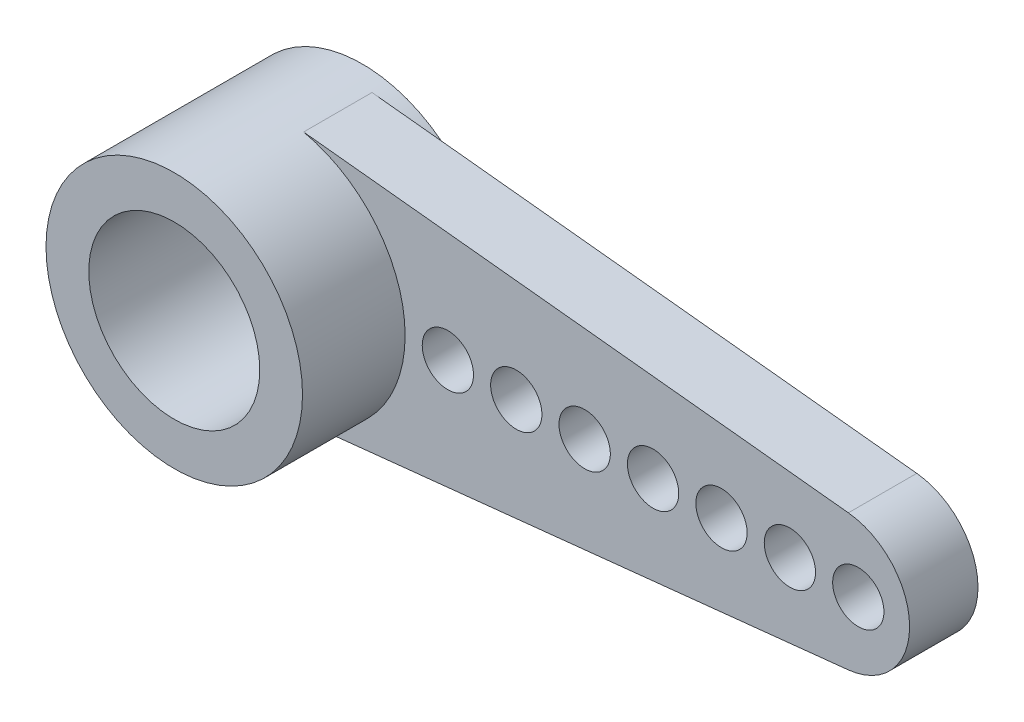
from build123d import *

# Parameters (mm, degrees)
EXTRUDE_3_DEPTH     = 2
SKETCH_2_R          = 3.75
SKETCH_2_R_2        = 2.5
EXTRUDE_5_DEPTH     = 3
SKETCH_3_R          = 3.75
SKETCH_3_R_2        = 2.5
EXTRUDE_6_DEPTH     = 2.5
SKETCH_4_R          = 0.75
CUT_EXTRUDE_1_DEPTH = 2
SKETCH_5_R          = 2.5
EXTRUDE_7_DEPTH     = 1
SKETCH_6_R          = 2.5
CUT_EXTRUDE_2_DEPTH = 0.5
SKETCH_7_R          = 1.25
CUT_EXTRUDE_3_DEPTH = 5


with BuildPart() as part:
    # Эскиз1 → Бобышка-Вытянуть3 (new body)
    with BuildSketch(Plane.XY):
        with BuildLine():
            Line((16.70961775, 1.988984766), (0.781737208, 3.667613248))
            ThreePointArc((0.781737208, 3.667613248), (2.914962652, 2.359129656), (3.75, 0))
            ThreePointArc((3.75, 0), (2.914962652, -2.359129656), (0.781737208, -3.667613248))
            Line((0.781737208, -3.667613248), (16.70961775, -1.988984766))
            ThreePointArc((16.70961775, -1.988984766), (18.5, 0), (16.70961775, 1.988984766))
        make_face()
    extrude(amount=EXTRUDE_3_DEPTH)



with BuildPart() as body_2:
    # Эскиз2 → Бобышка-Вытянуть5 (new body)
    with BuildSketch(Plane.XY.offset(2)):
        Circle(SKETCH_2_R)
        Circle(SKETCH_2_R_2, mode=Mode.SUBTRACT)
    extrude(amount=EXTRUDE_5_DEPTH)


with BuildPart() as part_1:
    add(part.part)

    add(body_2.part)  # Бобышка-Вытянуть6 merges body 2
    # Эскиз3 → Бобышка-Вытянуть6 (add)
    with BuildSketch(Plane(origin=(0, 0, 2), x_dir=(-1, 0, 0), z_dir=(0, 0, -1))):
        Circle(SKETCH_3_R)
        Circle(SKETCH_3_R_2, mode=Mode.SUBTRACT)
    extrude(amount=EXTRUDE_6_DEPTH)

    # Эскиз4 → Вырез-Вытянуть1 (cut)
    with BuildSketch(Plane(origin=(0, 0, 0), x_dir=(-1, 0, 0), z_dir=(0, 0, -1))):
        with Locations((-17, 0)):
            Circle(SKETCH_4_R)
        with Locations((-7, 0)):
            Circle(SKETCH_4_R)
        with Locations((-9, 0)):
            Circle(SKETCH_4_R)
        with Locations((-11, 0)):
            Circle(SKETCH_4_R)
        with Locations((-13, 0)):
            Circle(SKETCH_4_R)
        with Locations((-15, 0)):
            Circle(SKETCH_4_R)
        with Locations((-5, 0)):
            Circle(SKETCH_4_R)
    extrude(amount=-CUT_EXTRUDE_1_DEPTH, mode=Mode.SUBTRACT)

    # Эскиз5 → Бобышка-Вытянуть7 (add)
    with BuildSketch(Plane(origin=(0, 0, 0), x_dir=(-1, 0, 0), z_dir=(0, 0, -1))):
        Circle(SKETCH_5_R)
    extrude(amount=-EXTRUDE_7_DEPTH)

    # Эскиз6 → Вырез-Вытянуть2 (cut)
    with BuildSketch(Plane(origin=(0, 0, 0), x_dir=(-1, 0, 0), z_dir=(0, 0, -1))):
        Circle(SKETCH_6_R)
    extrude(amount=-CUT_EXTRUDE_2_DEPTH, mode=Mode.SUBTRACT)

    # Эскиз7 → Вырез-Вытянуть3 (cut)
    with BuildSketch(Plane(origin=(0, 0, 0.5), x_dir=(-1, 0, 0), z_dir=(0, 0, -1))):
        Circle(SKETCH_7_R)
    extrude(amount=-CUT_EXTRUDE_3_DEPTH, mode=Mode.SUBTRACT)


solid = part_1.part
